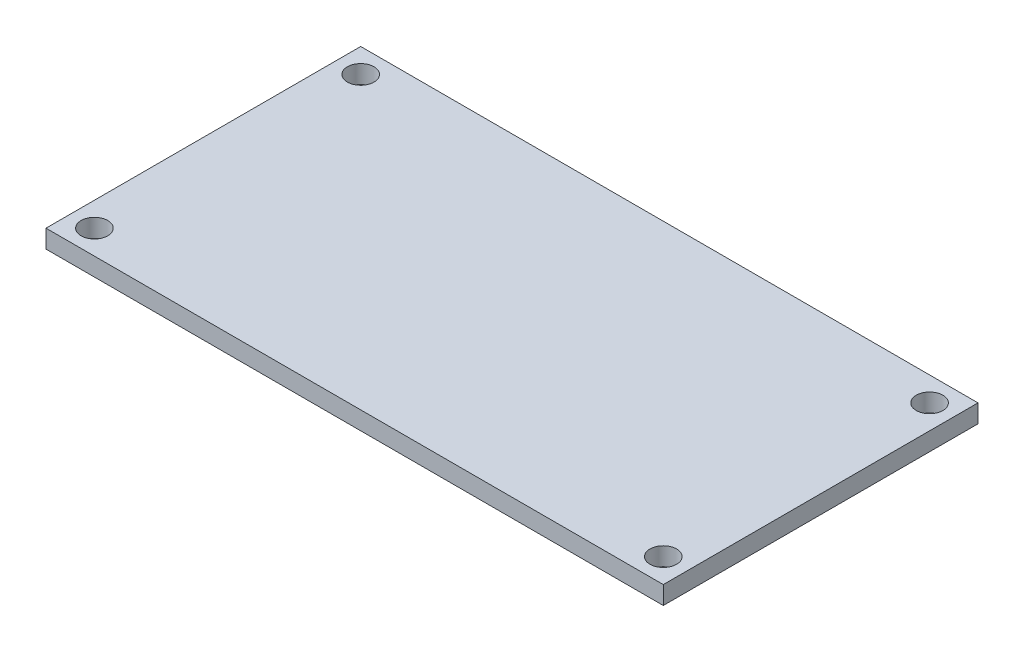
from build123d import *

# Parameters (mm, degrees)
SKETCH_1_W      = 51
SKETCH_1_H      = 26
SKETCH_1_R      = 1.1
EXTRUDE_1_DEPTH = 1.5


with BuildPart() as part:
    # Эскиз1 → Бобышка-Вытянуть1 (new body)
    with BuildSketch(Plane(origin=(0, 0, 0), x_dir=(1, 0, 0), z_dir=(0, 1, 0))):
        with Locations((25.5, 13)):
            Rectangle(SKETCH_1_W, SKETCH_1_H)
        with Locations((2, 2)):
            Circle(SKETCH_1_R, mode=Mode.SUBTRACT)
        with Locations((49, 2)):
            Circle(SKETCH_1_R, mode=Mode.SUBTRACT)
        with Locations((49, 24)):
            Circle(SKETCH_1_R, mode=Mode.SUBTRACT)
        with Locations((2, 24)):
            Circle(SKETCH_1_R, mode=Mode.SUBTRACT)
    extrude(amount=EXTRUDE_1_DEPTH)


solid = part.part
